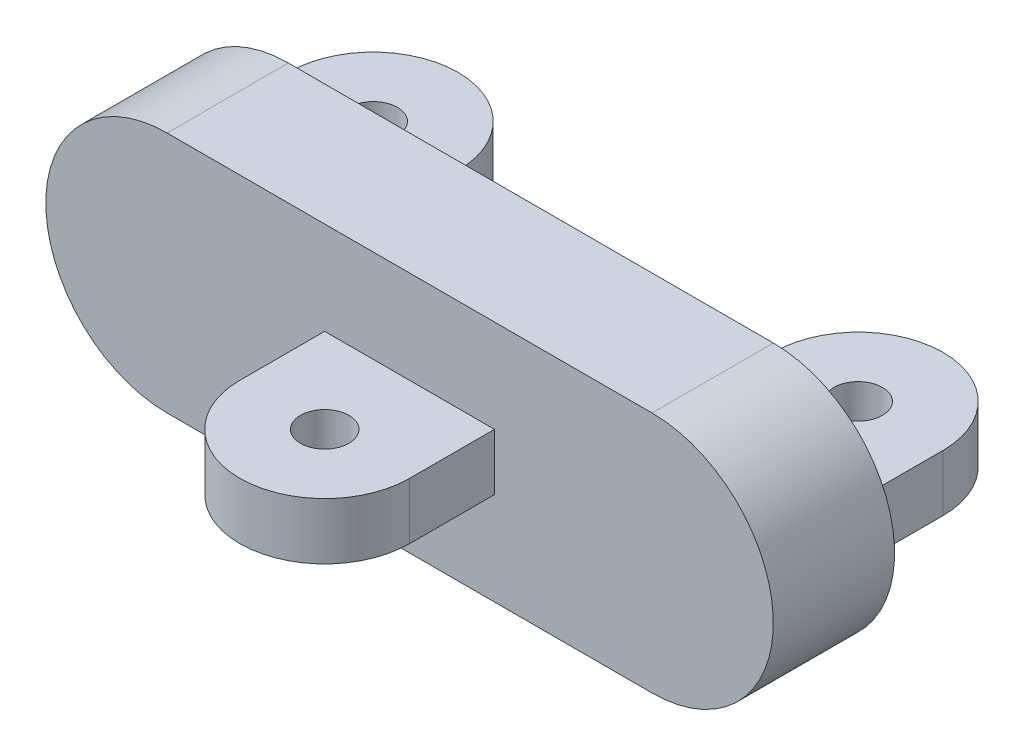
from build123d import *

# Parameters (mm, degrees)
BOSS_EXTRUDE1_DEPTH = 5
SKETCH3_W           = 7
SKETCH3_H           = 2.333333334
BOSS_EXTRUDE2_DEPTH = 3.5
SKETCH6_W           = 3.5
SKETCH6_H           = 2.333333334
REVOLVE1_ANGLE      = 180
CUT_EXTRUDE1_REACH  = 19.664
SKETCH7_R           = 1
SKETCH8_W           = 7
SKETCH8_H           = 2.33
BOSS_EXTRUDE3_DEPTH = 3.5
SKETCH9_W           = 3.5
SKETCH9_H           = 2.33
REVOLVE2_ANGLE      = 180
SKETCH9_3_W         = 3.5
SKETCH9_3_H         = 2.33
REVOLVE3_ANGLE      = 180
CUT_EXTRUDE2_REACH  = 22.174
SKETCH11_R          = 1


with BuildPart() as part:
    # Sketch2 → Boss-Extrude1 (new body)
    with BuildSketch(Plane.XY):
        with BuildLine():
            Line((-10, -5), (10, -5))
            ThreePointArc((10, -5), (15, 0), (10, 5))
            Line((10, 5), (-10, 5))
            ThreePointArc((-10, 5), (-15, 0), (-10, -5))
        make_face()
    extrude(amount=-BOSS_EXTRUDE1_DEPTH)

    # Sketch3 → Boss-Extrude2 (add)
    with BuildSketch(Plane.XY):
        Rectangle(SKETCH3_W, SKETCH3_H)
    extrude(amount=BOSS_EXTRUDE2_DEPTH)

    # Sketch6 → Revolve1 (revolve)
    with BuildSketch(Plane.XY.offset(3.5)):
        with Locations((-1.75, 0)):
            Rectangle(SKETCH6_W, SKETCH6_H)
    revolve(axis=Axis((0, 1.166666667, 3.5), (0, 1, 0)), revolution_arc=REVOLVE1_ANGLE)

    # Sketch7 → Cut-Extrude1 (cut, up to next)
    with BuildSketch(Plane(origin=(0, 1.166666667, 0), x_dir=(1, 0, 0), z_dir=(0, 1, 0)), mode=Mode.PRIVATE) as cut_extrude1_sk1:
        with Locations((0, -3.5)):
            Circle(SKETCH7_R)
    cut_extrude1_tool1 = extrude(cut_extrude1_sk1.sketch, amount=-CUT_EXTRUDE1_REACH, mode=Mode.PRIVATE) & part.part
    add(cut_extrude1_tool1.solids().sort_by_distance((0, 1.166667, 3.5))[0], mode=Mode.SUBTRACT)

    # Sketch8 → Boss-Extrude3 (add)
    with BuildSketch(Plane(origin=(0, 0, -5), x_dir=(-1, 0, 0), z_dir=(0, 0, -1))):
        with Locations((-10, 0)):
            Rectangle(SKETCH8_W, SKETCH8_H)
        with Locations((10, 0)):
            Rectangle(SKETCH8_W, SKETCH8_H)
    extrude(amount=BOSS_EXTRUDE3_DEPTH)

    # Sketch9 → Revolve2 (revolve)
    with BuildSketch(Plane(origin=(0, 0, -8.5), x_dir=(-1, 0, 0), z_dir=(0, 0, -1))):
        with Locations((-11.75, 0)):
            Rectangle(SKETCH9_W, SKETCH9_H)
    revolve(axis=Axis((10, 1.165, -8.5), (0, 1, 0)), revolution_arc=REVOLVE2_ANGLE)

    # Sketch9_3 → Revolve3 (revolve)
    with BuildSketch(Plane(origin=(0, 0, -8.5), x_dir=(-1, 0, 0), z_dir=(0, 0, -1))):
        with Locations((8.25, 0)):
            Rectangle(SKETCH9_3_W, SKETCH9_3_H)
    revolve(axis=Axis((-10, 1.165, -8.5), (0, 1, 0)), revolution_arc=REVOLVE3_ANGLE)

    # Sketch11 → Cut-Extrude2 (cut, up to next)
    with BuildSketch(Plane(origin=(0, 1.165, 0), x_dir=(1, 0, 0), z_dir=(0, 1, 0)), mode=Mode.PRIVATE) as cut_extrude2_sk1:
        with Locations((-10, 8.5)):
            Circle(SKETCH11_R)
    cut_extrude2_tool1 = extrude(cut_extrude2_sk1.sketch, amount=-CUT_EXTRUDE2_REACH, mode=Mode.PRIVATE) & part.part
    # Sketch11 → Cut-Extrude2 (cut, up to next)
    with BuildSketch(Plane(origin=(0, 1.165, 0), x_dir=(1, 0, 0), z_dir=(0, 1, 0)), mode=Mode.PRIVATE) as cut_extrude2_sk2:
        with Locations((10, 8.5)):
            Circle(SKETCH11_R)
    cut_extrude2_tool2 = extrude(cut_extrude2_sk2.sketch, amount=-CUT_EXTRUDE2_REACH, mode=Mode.PRIVATE) & part.part
    add(cut_extrude2_tool1.solids().sort_by_distance((-10, 1.165, -8.5))[0], mode=Mode.SUBTRACT)
    add(cut_extrude2_tool2.solids().sort_by_distance((10, 1.165, -8.5))[0], mode=Mode.SUBTRACT)


solid = part.part
